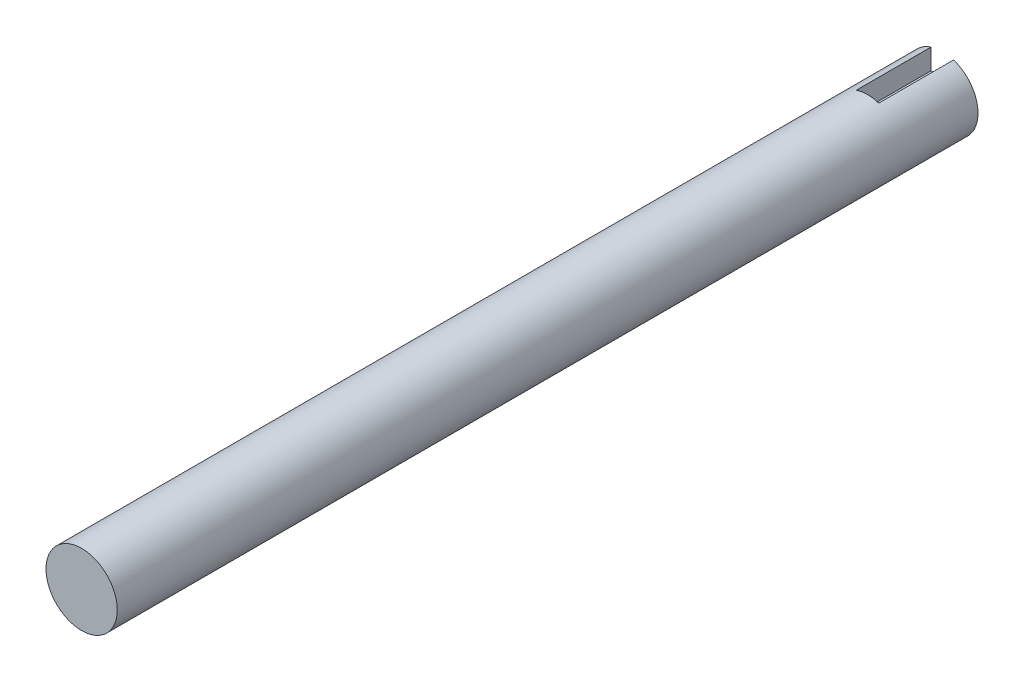
from build123d import *

# Parameters (mm, degrees)
SKETCH1_R           = 4.7625
BOSS_EXTRUDE1_DEPTH = 115
CUT_EXTRUDE1_DEPTH  = 10


with BuildPart() as part:
    # Sketch1 → Boss-Extrude1 (new body)
    with BuildSketch(Plane.XY):
        Circle(SKETCH1_R)
    extrude(amount=BOSS_EXTRUDE1_DEPTH)

    # Sketch1_3 → Cut-Extrude1 (cut)
    with BuildSketch(Plane.XY):
        with BuildLine():
            ThreePointArc((1.5, 4.520111309), (0, 4.7625), (-1.5, 4.520111309))
            Line((-1.5, 4.520111309), (-1.5, 1.7625))
            Line((-1.5, 1.7625), (1.5, 1.7625))
            Line((1.5, 1.7625), (1.5, 4.520111309))
        make_face()
    extrude(amount=CUT_EXTRUDE1_DEPTH, mode=Mode.SUBTRACT)


solid = part.part
